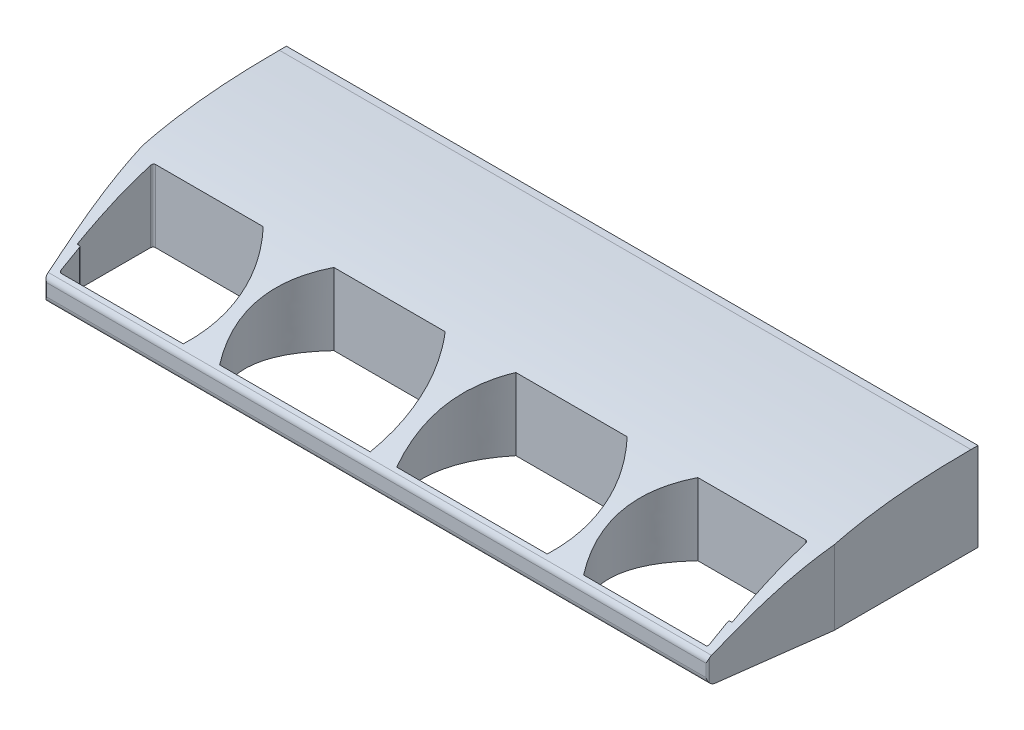
from build123d import *

# Parameters (mm, degrees)
BOSS_EXTRUDE1_DEPTH = 5
SKETCH5_W           = 39.175778664
SKETCH5_H           = 11.134274613
CUT_REVOLVE3_ANGLE  = 30
CUT_EXTRUDE2_DEPTH  = 50


with BuildPart() as part:
    # Sketch2 → Boss-Extrude1 (new body)
    with BuildSketch(Plane(origin=(0, 0, 0), x_dir=(1, 0, 0), z_dir=(0, 1, 0))):
        with BuildLine():
            Line((-19.587889332, 4.75), (-19.587889332, 12.891151468))
            Line((-19.587889332, 12.891151468), (19.587889332, 12.891151468))
            Line((19.587889332, 12.891151468), (19.587889332, 4.75))
            Line((19.587889332, 4.75), (18.770336665, -1.514246746))
            ThreePointArc((18.770336665, -1.514246746), (18.737154352, -1.576452374), (18.671177592, -1.601305403))
            Line((18.671177592, -1.601305403), (-18.671177592, -1.601305403))
            ThreePointArc((-18.671177592, -1.601305403), (-18.737154352, -1.576452374), (-18.770336665, -1.514246746))
            Line((-18.770336665, -1.514246746), (-19.587889332, 4.75))
        make_face()
        with BuildLine():
            Line((18.41371442, 0), (18.5, 0))
            ThreePointArc((18.5, 0), (18.535355339, 0.014644661), (18.55, 0.05))
            Line((18.55, 0.05), (18.55, 4.15))
            ThreePointArc((18.55, 4.15), (18.506066017, 4.256066017), (18.4, 4.3))
            Line((18.4, 4.3), (12.307916791, 4.3))
            add(Edge.make_bspline(
                [(12.307916791, 4.3), (9.637425056, 1.440271055), (11.338639539, -1.2)],
                knots=[0, 0, 0, 1, 1, 1], degree=2))
            Line((11.338639539, -1.2), (18.26371442, -1.2))
            ThreePointArc((18.26371442, -1.2), (18.334425098, -1.170710678), (18.36371442, -1.1))
            Line((18.36371442, -1.1), (18.36371442, -0.05))
            ThreePointArc((18.36371442, -0.05), (18.378359081, -0.014644661), (18.41371442, 0))
        make_face(mode=Mode.SUBTRACT)
        with BuildLine():
            Line((-2, 4.3), (-8.307916791, 4.3))
            add(Edge.make_bspline(
                [(-8.307916791, 4.3), (-10.978408526, 1.440271055), (-9.277194043, -1.2)],
                knots=[0, 0, 0, 1, 1, 1], degree=2))
            Line((-9.277194043, -1.2), (-0.75, -1.2))
            add(Edge.make_bspline(
                [(-2, 4.3), (0.166282415, 1.650512873), (-0.75, -1.2)],
                knots=[0, 0, 0, 1, 1, 1], degree=2))
        make_face(mode=Mode.SUBTRACT)
        with BuildLine():
            Line((9.277194043, -1.2), (0.75, -1.2))
            add(Edge.make_bspline(
                [(2, 4.3), (-0.166282415, 1.650512873), (0.75, -1.2)],
                knots=[0, 0, 0, 1, 1, 1], degree=2))
            Line((2, 4.3), (8.307916791, 4.3))
            add(Edge.make_bspline(
                [(8.307916791, 4.3), (10.978408526, 1.440271055), (9.277194043, -1.2)],
                knots=[0, 0, 0, 1, 1, 1], degree=2))
        make_face(mode=Mode.SUBTRACT)
        with BuildLine():
            Line((-12.307916791, 4.3), (-18.4, 4.3))
            ThreePointArc((-18.4, 4.3), (-18.506066017, 4.256066017), (-18.55, 4.15))
            Line((-18.55, 4.15), (-18.55, 0.05))
            ThreePointArc((-18.55, 0.05), (-18.535355339, 0.014644661), (-18.5, 0))
            Line((-18.5, 0), (-18.41371442, 0))
            ThreePointArc((-18.41371442, 0), (-18.378359081, -0.014644661), (-18.36371442, -0.05))
            Line((-18.36371442, -0.05), (-18.36371442, -1.1))
            ThreePointArc((-18.36371442, -1.1), (-18.334425098, -1.170710678), (-18.26371442, -1.2))
            Line((-18.26371442, -1.2), (-11.338639539, -1.2))
            add(Edge.make_bspline(
                [(-12.307916791, 4.3), (-9.637425056, 1.440271055), (-11.338639539, -1.2)],
                knots=[0, 0, 0, 1, 1, 1], degree=2))
        make_face(mode=Mode.SUBTRACT)
    extrude(amount=BOSS_EXTRUDE1_DEPTH)

    # Sketch5 → Cut-Revolve3 (revolve, cut)
    with BuildSketch(Plane(origin=(0, 5, 0), x_dir=(1, 0, 0), z_dir=(0, 1, 0))):
        with Locations((0, -0.817137307)):
            Rectangle(SKETCH5_W, SKETCH5_H)
    revolve(axis=Axis((-19.587889332, 5, -4.75), (1, 0, 0)), revolution_arc=CUT_REVOLVE3_ANGLE, mode=Mode.SUBTRACT)

    # Sketch8 → Cut-Extrude2 (cut)
    with BuildSketch(Plane.ZY.offset(19.587889332)):
        Polygon((4.230476996, 7.111214782), (-14.213063749, 7.925673134), (-16.866621606, -3.135196744), (3.547382894, -3.844563695), align=None)
        with BuildLine():
            Line((-12.891151468, 0), (-12.891151468, 0.4))
            Line((-12.891151468, 0.4), (-12.891151468, 4.6))
            Line((-12.891151468, 4.6), (-12.891151468, 5))
            Line((-12.891151468, 5), (-12.491151468, 5))
            Line((-12.491151468, 5), (-4.75, 5))
            Line((-4.75, 5), (-4.75, 4.203963132))
            add(Edge.make_bspline(
                [(-4.75, 4.203963132), (-2.254573222, 3.559264678), (-0.743625983, 2.686918883), (0.627090158, 1.89553555), (1.401305403, 1.448542169)],
                knots=[0.350361042, 0.350361042, 0.350361042, 0.350361042, 0.350361042, 1, 1, 1, 1, 1], degree=4))
            ThreePointArc((1.401305403, 1.448542169), (1.547715565, 1.302132008), (1.601305403, 1.102132008))
            Line((1.601305403, 1.102132008), (1.601305403, 0.4))
            ThreePointArc((1.601305403, 0.4), (1.484148116, 0.117157288), (1.201305403, 0))
            Line((1.201305403, 0), (-4.75, 0))
            Line((-4.75, 0), (-12.491151468, 0))
            Line((-12.491151468, 0), (-12.891151468, 0))
        make_face(mode=Mode.SUBTRACT)
        with BuildLine():
            Line((-4.75, 5), (-12.491151468, 5))
            add(Edge.make_bspline(
                [(-12.491151468, 5), (-9.778953574, 5), (-7.727997949, 4.833142186), (-6.095824962, 4.551659678), (-4.75, 4.203963132)],
                knots=[0, 0, 0, 0, 0, 0.350361042, 0.350361042, 0.350361042, 0.350361042, 0.350361042], degree=4))
            Line((-4.75, 4.203963132), (-4.75, 5))
        make_face()
    extrude(amount=-CUT_EXTRUDE2_DEPTH, mode=Mode.SUBTRACT)


solid = part.part
